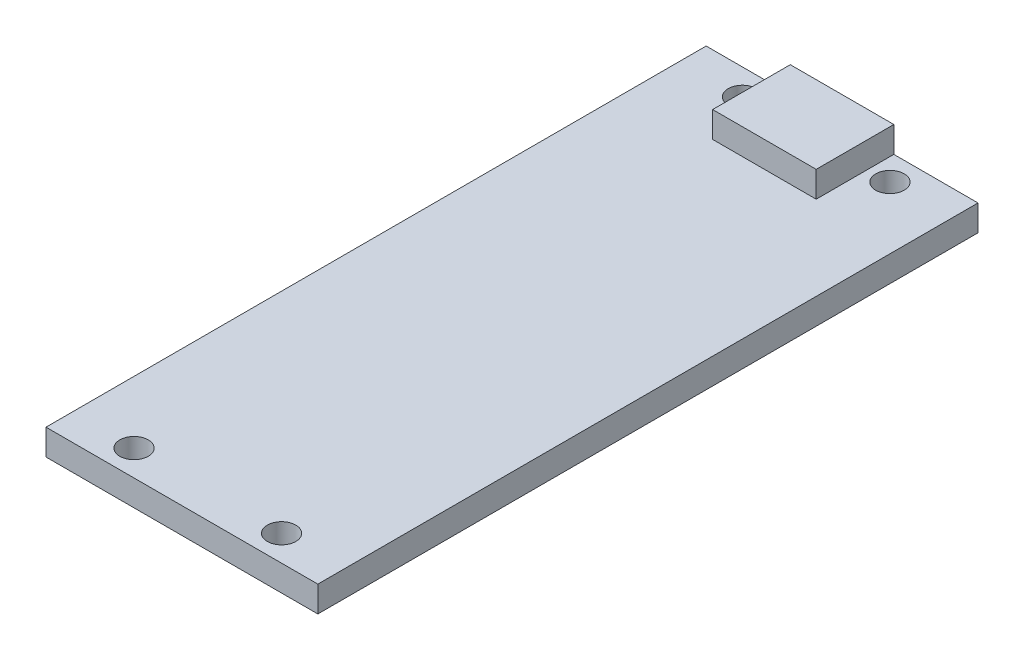
from build123d import *

# Parameters (mm, degrees)
SKETCH1_W           = 21
SKETCH1_H           = 51
BOSS_EXTRUDE1_DEPTH = 2
SKETCH2_W           = 8
SKETCH2_H           = 6
BOSS_EXTRUDE2_DEPTH = 2
SKETCH3_R           = 1.1
CUT_EXTRUDE1_DEPTH  = 2


with BuildPart() as part:
    # Sketch1 → Boss-Extrude1 (new body)
    with BuildSketch(Plane(origin=(0, 0, 0), x_dir=(1, 0, 0), z_dir=(0, 1, 0))):
        Rectangle(SKETCH1_W, SKETCH1_H)
    extrude(amount=BOSS_EXTRUDE1_DEPTH)

    # Sketch2 → Boss-Extrude2 (add)
    with BuildSketch(Plane(origin=(0, 2, 0), x_dir=(1, 0, 0), z_dir=(0, 1, 0))):
        with Locations((0, 22.5)):
            Rectangle(SKETCH2_W, SKETCH2_H)
    extrude(amount=BOSS_EXTRUDE2_DEPTH)

    # Sketch3 → Cut-Extrude1 (cut)
    with BuildSketch(Plane(origin=(0, 2, 0), x_dir=(1, 0, 0), z_dir=(0, 1, 0))):
        with Locations((-5.7, 23.5)):
            Circle(SKETCH3_R)
        with Locations((5.7, 23.5)):
            Circle(SKETCH3_R)
        with Locations((-5.7, -23.5)):
            Circle(SKETCH3_R)
        with Locations((5.7, -23.5)):
            Circle(SKETCH3_R)
    extrude(amount=-CUT_EXTRUDE1_DEPTH, mode=Mode.SUBTRACT)


solid = part.part
